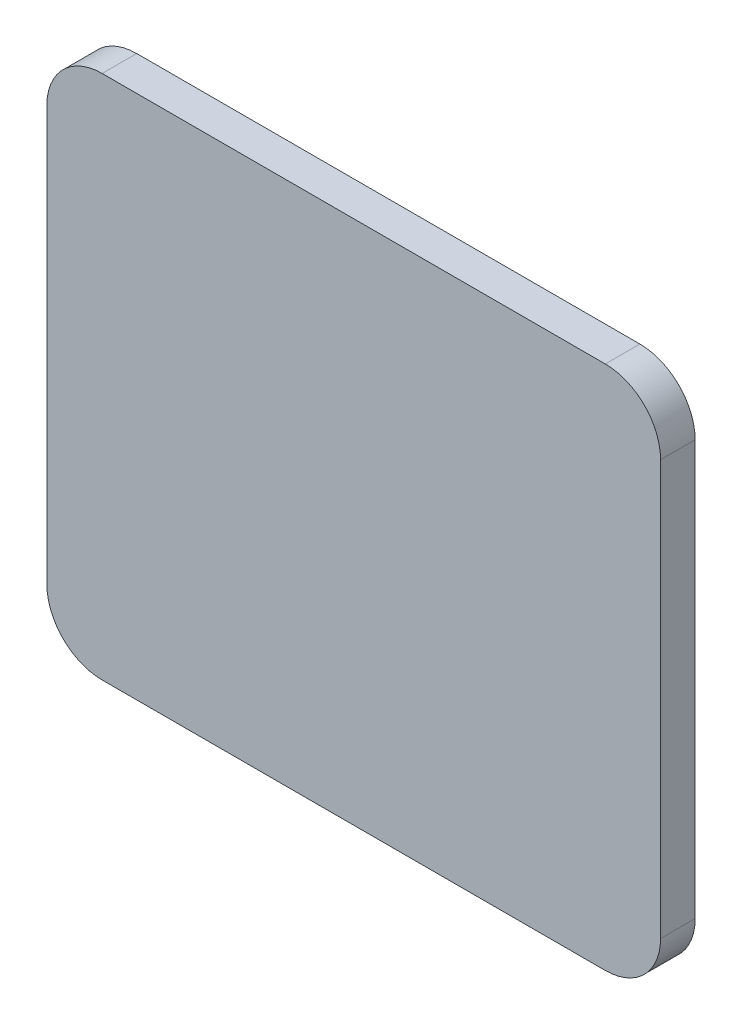
from build123d import *

# Parameters (mm, degrees)
BOSS_EXTRUDE1_DEPTH = 1.5875


with BuildPart() as part:
    # Sketch1 → Boss-Extrude1 (new body)
    with BuildSketch(Plane.XY):
        with BuildLine():
            Line((11.557, -12.065), (-11.557, -12.065))
            ThreePointArc((-11.557, -12.065), (-13.353051224, -11.321051224), (-14.097, -9.525))
            Line((-14.097, -9.525), (-14.097, 9.525))
            ThreePointArc((-14.097, 9.525), (-13.353051224, 11.321051224), (-11.557, 12.065))
            Line((-11.557, 12.065), (11.557, 12.065))
            ThreePointArc((11.557, 12.065), (13.353051224, 11.321051224), (14.097, 9.525))
            Line((14.097, 9.525), (14.097, -9.525))
            ThreePointArc((14.097, -9.525), (13.353051224, -11.321051224), (11.557, -12.065))
        make_face()
    extrude(amount=BOSS_EXTRUDE1_DEPTH)


solid = part.part
